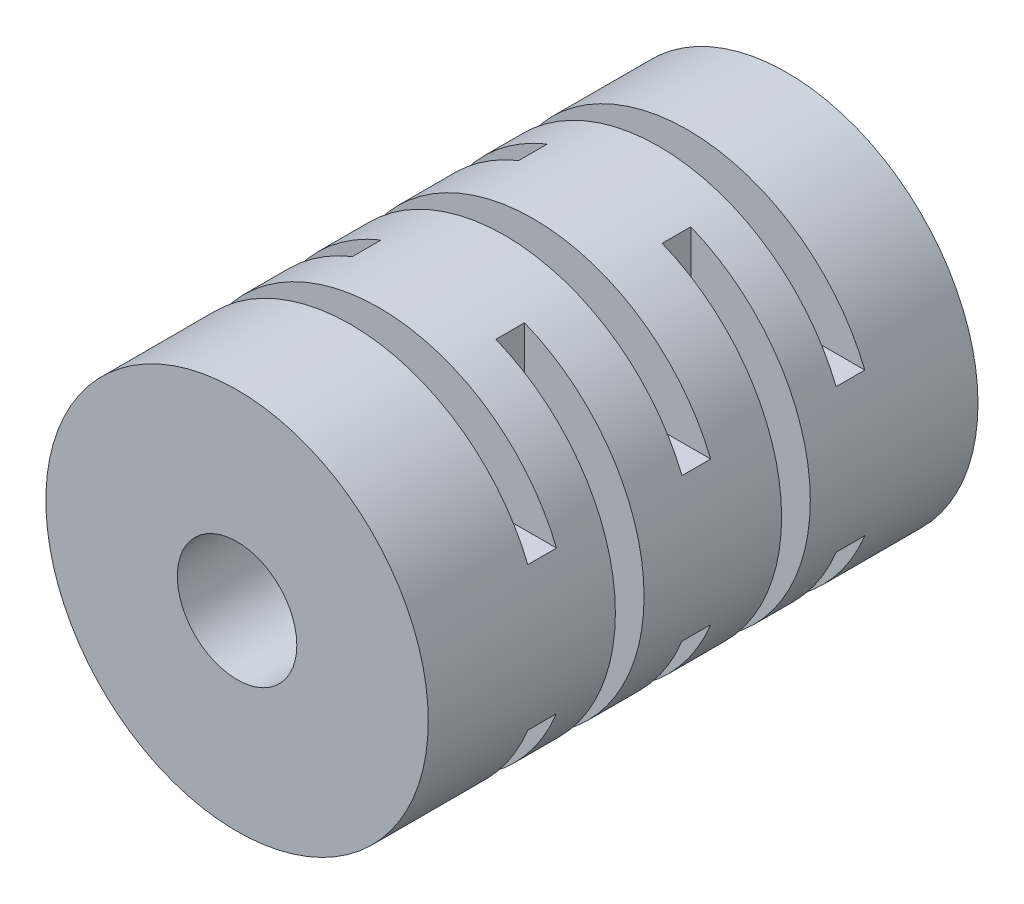
from build123d import *

# Parameters (mm, degrees)
SKETCH1_R           = 8
SKETCH1_R_2         = 2.5
BOSS_EXTRUDE1_DEPTH = 23
SKETCH2_W           = 12.136901607
SKETCH2_H           = 1.2
SKETCH2_W_2         = 11.75463699
CUT_EXTRUDE1_DEPTH  = 9
CIRPATTERN1_COUNT   = 2
SKETCH3_W           = 1.2
SKETCH3_H           = 8.369278369
SKETCH3_H_2         = 8.338508964
SKETCH3_H_3         = 7.969276094
CUT_EXTRUDE2_DEPTH  = 9
CIRPATTERN2_COUNT   = 2


with BuildPart() as part:
    # Sketch1 → Boss-Extrude1 (new body)
    with BuildSketch(Plane.XY):
        Circle(SKETCH1_R)
        Circle(SKETCH1_R_2, mode=Mode.SUBTRACT)
    extrude(amount=BOSS_EXTRUDE1_DEPTH)

    # Sketch2 → Cut-Extrude1 (cut, symmetric)
    with BuildSketch(Plane(origin=(0, 0, 0), x_dir=(1, 0, 0), z_dir=(0, 1, 0))):
        with Locations((-9.068450803, -7.616722674)):
            Rectangle(SKETCH2_W, SKETCH2_H)
        with Locations((-8.877318495, -14.571215167)):
            Rectangle(SKETCH2_W_2, SKETCH2_H)
    cut_extrude1 = extrude(amount=CUT_EXTRUDE1_DEPTH, both=True, mode=Mode.SUBTRACT)

    # CirPattern1: Cut-Extrude1 ×2 about axis
    cirpattern1_axis = Axis((0, 0, 23), (0, 0, -1))
    for i in range(1, CIRPATTERN1_COUNT):
        add(cut_extrude1.rotate(cirpattern1_axis, i * 360 / CIRPATTERN1_COUNT), mode=Mode.SUBTRACT)

    # Sketch3 → Cut-Extrude2 (cut, symmetric)
    with BuildSketch(Plane(origin=(0, 0, 0), x_dir=(0, 0, -1), z_dir=(1, 0, 0))):
        with Locations((-11.201145593, 7.184639184)):
            Rectangle(SKETCH3_W, SKETCH3_H)
        with Locations((-17.65104418, 7.169254482)):
            Rectangle(SKETCH3_W, SKETCH3_H_2)
        with Locations((-4.751247006, 6.984638047)):
            Rectangle(SKETCH3_W, SKETCH3_H_3)
    cut_extrude2 = extrude(amount=CUT_EXTRUDE2_DEPTH, both=True, mode=Mode.SUBTRACT)

    # CirPattern2: Cut-Extrude2 ×2 about axis
    cirpattern2_axis = Axis((0, 0, 23), (0, 0, -1))
    for i in range(1, CIRPATTERN2_COUNT):
        add(cut_extrude2.rotate(cirpattern2_axis, i * 360 / CIRPATTERN2_COUNT), mode=Mode.SUBTRACT)


solid = part.part
